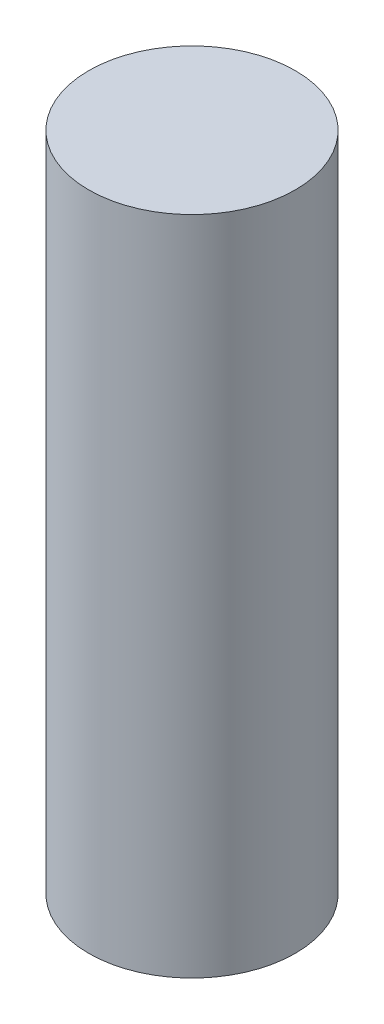
from build123d import *

# Parameters (mm, degrees)
SKETCH1_R           = 9.525
BOSS_EXTRUDE1_DEPTH = 60.96


with BuildPart() as part:
    # Sketch1 → Boss-Extrude1 (new body)
    with BuildSketch(Plane(origin=(0, 0, 0), x_dir=(1, 0, 0), z_dir=(0, 1, 0))):
        Circle(SKETCH1_R)
    extrude(amount=BOSS_EXTRUDE1_DEPTH)


solid = part.part
